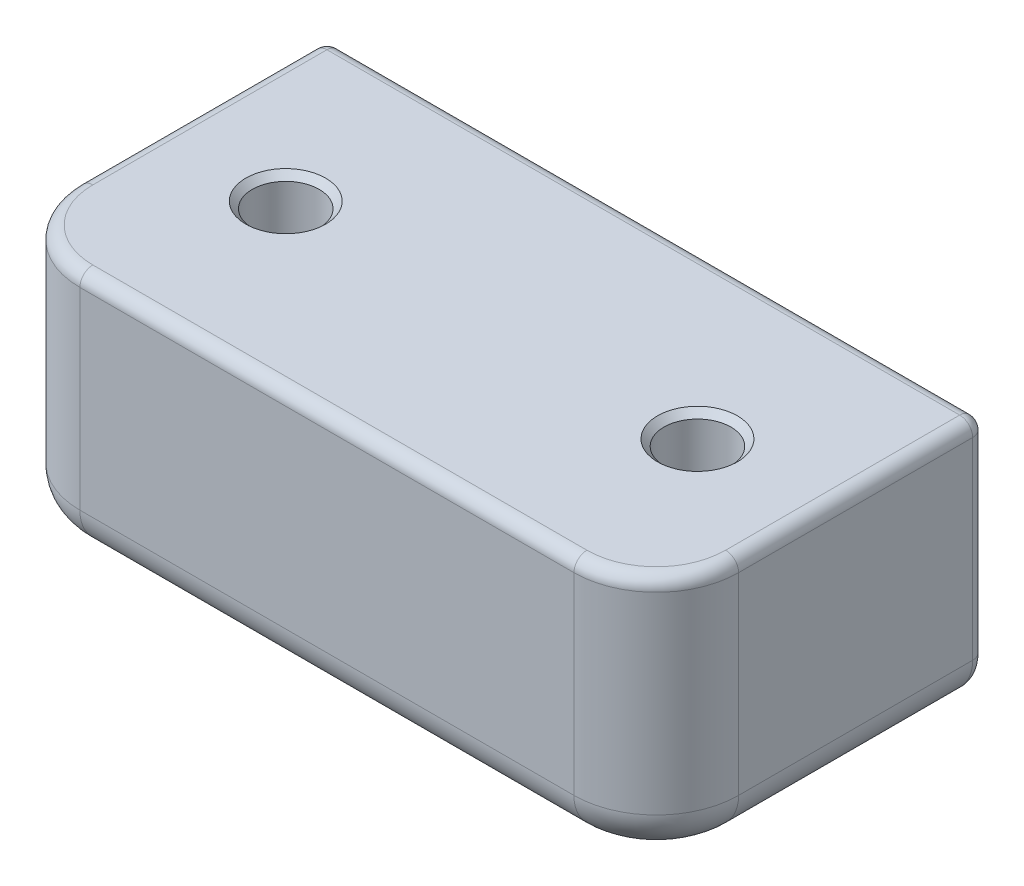
from build123d import *

# Parameters (mm, degrees)
BOSS_EXTRUDE1_DEPTH = 19.05
SKETCH2_R           = 2.5796875
CUT_EXTRUDE1_DEPTH  = 20.05
SKETCH3_R           = 6.604
CUT_EXTRUDE2_DEPTH  = 6.604
CHAMFER1_SIZE       = 0.5
FILLET1_R           = 3.175
FILLET2_R           = 1


with BuildPart() as part:
    # Sketch1 → Boss-Extrude1 (new body)
    with BuildSketch(Plane(origin=(0, 0, 0), x_dir=(1, 0, 0), z_dir=(0, 1, 0))):
        with BuildLine():
            Line((6.35, 0), (44.45, 0))
            ThreePointArc((44.45, 0), (48.940128061, 1.859871939), (50.8, 6.35))
            Line((50.8, 6.35), (50.8, 25.4))
            Line((50.8, 25.4), (0, 25.4))
            Line((0, 25.4), (0, 6.35))
            ThreePointArc((0, 6.35), (1.859871939, 1.859871939), (6.35, 0))
        make_face()
    extrude(amount=BOSS_EXTRUDE1_DEPTH)

    # Sketch2 → Cut-Extrude1 (cut, through all)
    with BuildSketch(Plane(origin=(0, 19.05, 0), x_dir=(1, 0, 0), z_dir=(0, 1, 0))):
        with Locations(Location((9.525, 12.7, 0), (0, 0, 270))):  # turned: the seam where the file's is
            Circle(SKETCH2_R)
        with Locations(Location((41.275, 12.7, 0), (0, 0, 90))):  # turned: the seam where the file's is
            Circle(SKETCH2_R)
    extrude(amount=-CUT_EXTRUDE1_DEPTH, mode=Mode.SUBTRACT)

    # Sketch3 → Cut-Extrude2 (cut)
    with BuildSketch(Plane(origin=(0, 0, -25.4), x_dir=(-1, 0, 0), z_dir=(0, 0, -1))):
        with Locations((-41.275, 9.525)):
            Circle(SKETCH3_R)
        with Locations(Location((-9.525, 9.525, 0), (0, 0, 180))):  # turned: the seam where the file's is
            Circle(SKETCH3_R)
    extrude(amount=-CUT_EXTRUDE2_DEPTH, mode=Mode.SUBTRACT)

    # Chamfer1
    chamfer1_edges = [part.edges().sort_by_distance(p)[0] for p in [
        (9.525, 0, -15.2796875),
        (9.525, 19.05, -15.2796875),
        (41.275, 0, -10.1203125),
        (41.275, 19.05, -10.1203125),
        (47.879, 9.525, -25.4),
        (2.921, 9.525, -25.4),
    ]]
    chamfer(chamfer1_edges, length=CHAMFER1_SIZE)

    # Fillet1
    fillet1_edges = [part.edges().sort_by_distance(p)[0] for p in [
        (48.940128061, 0, -1.859871939),
        (25.4, 0, 0),
        (1.859871939, 0, -1.859871939),
        (0, 0, -15.875),
        (50.8, 0, -15.875),
    ]]
    fillet(fillet1_edges, radius=FILLET1_R)

    # Fillet2
    fillet2_edges = [part.edges().sort_by_distance(p)[0] for p in [
        (0, 19.05, -15.875),
        (0, 11.1125, -25.4),
        (50.8, 11.1125, -25.4),
        (1.859871939, 19.05, -1.859871939),
        (25.4, 19.05, 0),
        (48.940128061, 19.05, -1.859871939),
        (50.8, 19.05, -15.875),
        (25.4, 0, -25.4),
        (49.87006403, 0.92993597, -25.4),
        (0.92993597, 0.92993597, -25.4),
        (25.4, 19.05, -25.4),
    ]]
    fillet(fillet2_edges, radius=FILLET2_R)


solid = part.part
